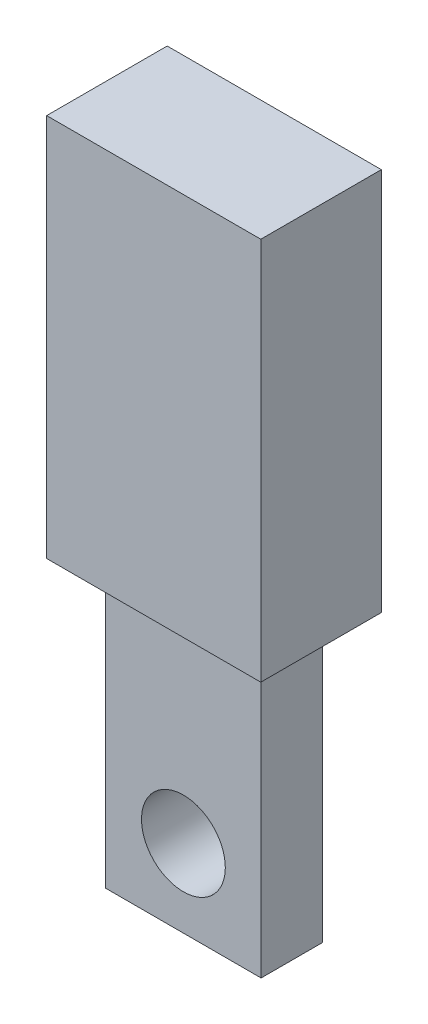
from build123d import *

# Parameters (mm, degrees)
SKETCH1_W               = 64.516
SKETCH1_H               = 25.4
EXTRUDE2_DEPTH          = 59.309
EXTRUDE2_DEPTH_BACK     = 59.309
SKETCH2_R               = 17.399
CUT_EXTRUDE1_DEPTH      = 13.7
CUT_EXTRUDE1_DEPTH_BACK = 13.7
SKETCH3_W               = 88.9
SKETCH3_H               = 50.038
EXTRUDE3_DEPTH          = 159.258


with BuildPart() as part:
    # Sketch1 → Extrude2 (new body, two sides)
    with BuildSketch(Plane(origin=(0, 0, 0), x_dir=(1, 0, 0), z_dir=(0, 1, 0))) as extrude2_sk:
        Rectangle(SKETCH1_W, SKETCH1_H)
    extrude(amount=EXTRUDE2_DEPTH)
    extrude(extrude2_sk.sketch, amount=-EXTRUDE2_DEPTH_BACK)

    # Sketch2 → Cut-Extrude1 (cut, two sides)
    with BuildSketch(Plane.XY) as cut_extrude1_sk:
        with Locations((0, -27.051)):
            Circle(SKETCH2_R)
    extrude(amount=CUT_EXTRUDE1_DEPTH, mode=Mode.SUBTRACT)
    extrude(cut_extrude1_sk.sketch, amount=-CUT_EXTRUDE1_DEPTH_BACK, mode=Mode.SUBTRACT)

    # Sketch3 → Extrude3 (add)
    with BuildSketch(Plane(origin=(0, 59.309, 0), x_dir=(-1, 0, 0), z_dir=(0, 1, 0))):
        Rectangle(SKETCH3_W, SKETCH3_H)
    extrude(amount=EXTRUDE3_DEPTH)


solid = part.part
